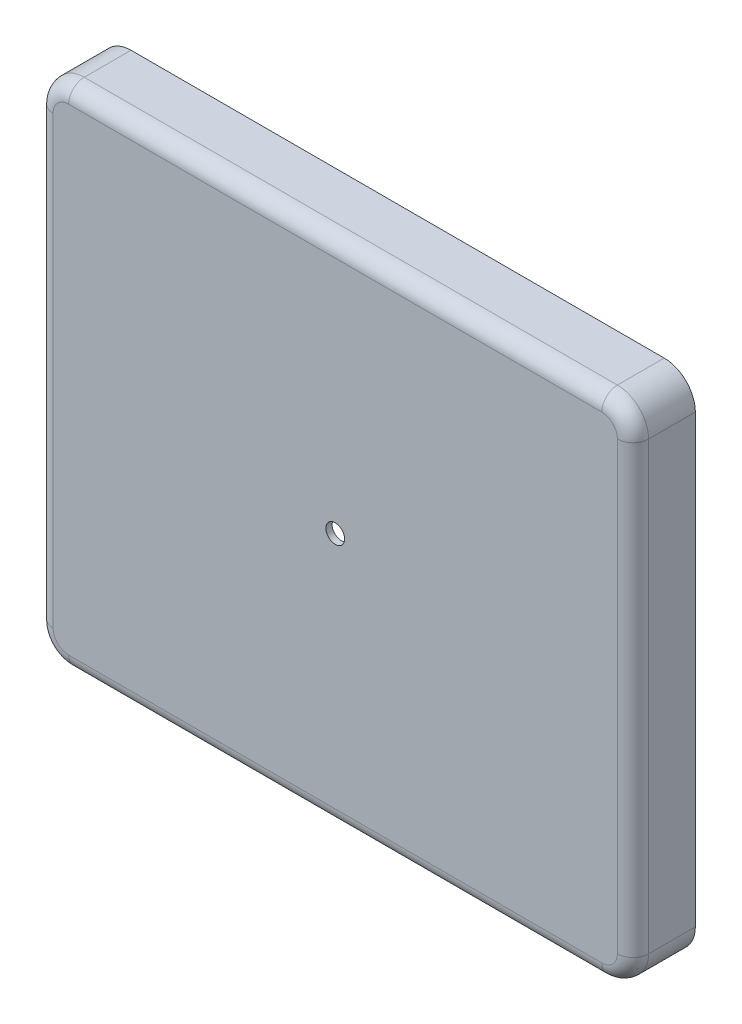
from build123d import *

# Parameters (mm, degrees)
SKETCH1_W           = 191
SKETCH1_H           = 163
BOSS_EXTRUDE1_DEPTH = 20
FILLET1_R           = 10
FILLET2_R           = 5
SHELL1_T            = -2
SKETCH2_R           = 3
CUT_EXTRUDE1_DEPTH  = 10


with BuildPart() as part:
    # Sketch1 → Boss-Extrude1 (new body)
    with BuildSketch(Plane.XY):
        Rectangle(SKETCH1_W, SKETCH1_H)
    extrude(amount=BOSS_EXTRUDE1_DEPTH)

    # Fillet1
    fillet1_edges = [part.edges().sort_by_distance(p)[0] for p in [
        (95.5, -81.5, 10),
        (-95.5, -81.5, 10),
        (-95.5, 81.5, 10),
        (95.5, 81.5, 10),
    ]]
    fillet(fillet1_edges, radius=FILLET1_R)

    # Fillet2
    fillet2_edges = [part.edges().sort_by_distance(p)[0] for p in [
        (0, -81.5, 20),
        (-95.5, 0, 20),
        (95.5, 0, 20),
        (0, 81.5, 20),
        (-92.571067812, 78.571067812, 20),
        (92.571067812, 78.571067812, 20),
        (92.571067812, -78.571067812, 20),
        (-92.571067812, -78.571067812, 20),
    ]]
    fillet(fillet2_edges, radius=FILLET2_R)

    # Shell1
    shell1_openings = [part.faces().sort_by_distance(p)[0] for p in [
        (0, 0, 0),
    ]]
    offset(amount=SHELL1_T, openings=shell1_openings, kind=Kind.INTERSECTION)

    # Sketch2 → Cut-Extrude1 (cut)
    with BuildSketch(Plane(origin=(0, 0, 18), x_dir=(-1, 0, 0), z_dir=(0, 0, -1))):
        Circle(SKETCH2_R)
    extrude(amount=-CUT_EXTRUDE1_DEPTH, mode=Mode.SUBTRACT)


solid = part.part
